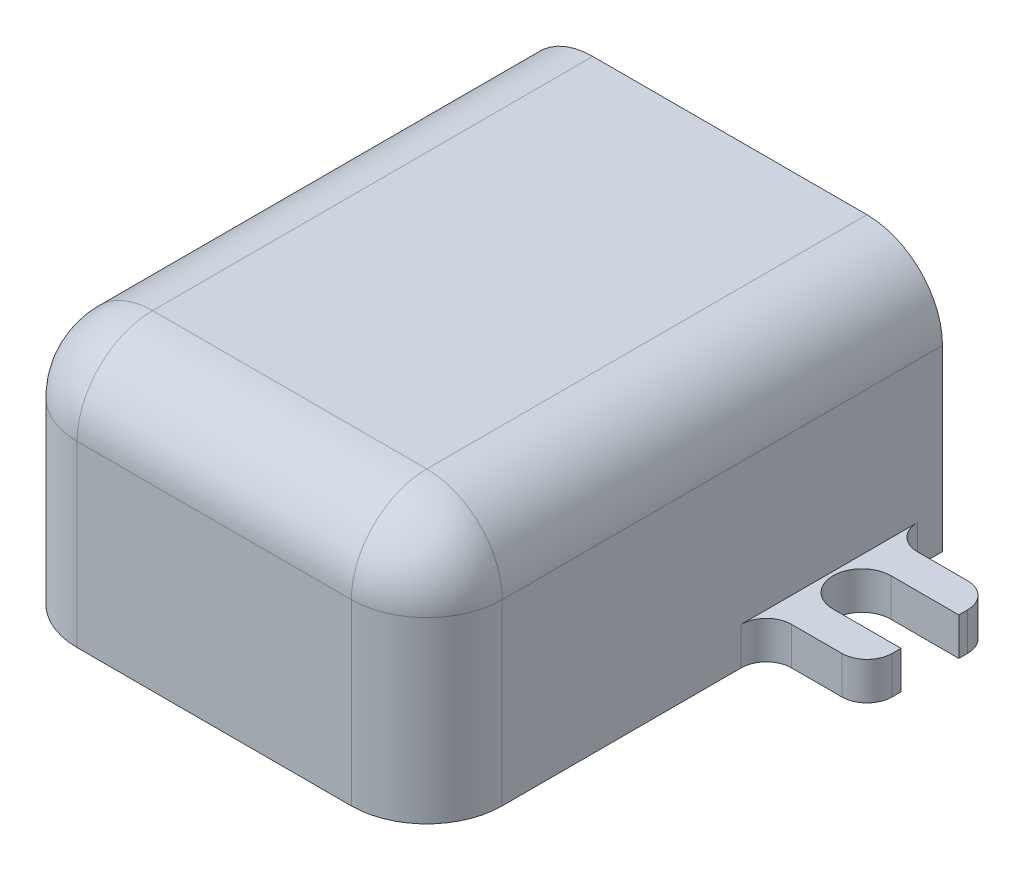
from build123d import *

# Parameters (mm, degrees)
SKETCH1_W           = 16.9
SKETCH1_H           = 20.5
BOSS_EXTRUDE1_DEPTH = 1.5
SKETCH2_W           = 16.9
SKETCH2_H           = 20.5
BOSS_EXTRUDE2_DEPTH = 8.6
FILLET1_R           = 3
FILLET2_R           = 1
SKETCH3_R           = 1.5
CUT_EXTRUDE1_DEPTH  = 10


with BuildPart() as part:
    # Sketch1 → Boss-Extrude1 (new body)
    with BuildSketch(Plane(origin=(0, 0, 0), x_dir=(1, 0, 0), z_dir=(0, 1, 0))):
        with BuildLine():
            Line((-8.45, 3.25), (-8.45, 8.25))
            Line((-8.45, 8.25), (-12.45, 8.25))
            Line((-12.45, 8.25), (-12.45, 6.9))
            Line((-12.45, 6.9), (-9.75, 6.9))
            ThreePointArc((-9.75, 6.9), (-8.936827202, 6.563172798), (-8.6, 5.75))
            ThreePointArc((-8.6, 5.75), (-8.936827202, 4.936827202), (-9.75, 4.6))
            Line((-9.75, 4.6), (-12.45, 4.6))
            Line((-12.45, 4.6), (-12.45, 3.25))
            Line((-12.45, 3.25), (-8.45, 3.25))
        make_face()
        Rectangle(SKETCH1_W, SKETCH1_H)
        with BuildLine():
            Line((12.45, 8.25), (8.45, 8.25))
            Line((8.45, 8.25), (8.45, 3.25))
            Line((8.45, 3.25), (12.45, 3.25))
            Line((12.45, 3.25), (12.45, 4.6))
            Line((12.45, 4.6), (9.75, 4.6))
            ThreePointArc((9.75, 4.6), (8.6, 5.75), (9.75, 6.9))
            Line((9.75, 6.9), (12.45, 6.9))
            Line((12.45, 6.9), (12.45, 8.25))
        make_face()
    extrude(amount=BOSS_EXTRUDE1_DEPTH)

    # Sketch2 → Boss-Extrude2 (add)
    with BuildSketch(Plane(origin=(0, 1.5, 0), x_dir=(1, 0, 0), z_dir=(0, 1, 0))):
        Rectangle(SKETCH2_W, SKETCH2_H)
    extrude(amount=BOSS_EXTRUDE2_DEPTH)

    # Fillet1
    fillet1_edges = [part.edges().sort_by_distance(p)[0] for p in [
        (8.45, 5.05, 10.25),
        (-8.45, 5.05, 10.25),
        (-8.45, 10.1, 0),
        (0, 10.1, 10.25),
        (8.45, 10.1, 0),
    ]]
    fillet(fillet1_edges, radius=FILLET1_R)

    # Fillet2
    fillet2_edges = [part.edges().sort_by_distance(p)[0] for p in [
        (-12.45, 0.75, -8.25),
        (-8.45, 0.75, -8.25),
        (8.45, 0.75, -8.25),
        (12.45, 0.75, -8.25),
        (12.45, 0.75, -3.25),
        (8.45, 0.75, -3.25),
        (-8.45, 0.75, -3.25),
        (-12.45, 0.75, -3.25),
    ]]
    fillet(fillet2_edges, radius=FILLET2_R)

    # Sketch3 → Cut-Extrude1 (cut)
    with BuildSketch(Plane(origin=(0, 0, -10.25), x_dir=(-1, 0, 0), z_dir=(0, 0, -1))):
        Polygon((7.5, 4.05), (7.5, 6.05), (6, 7.55), (-7.5, 7.55), (-7.5, 2.55), (6, 2.55), align=None)
        with Locations((-3.6, 5.05)):
            Circle(SKETCH3_R, mode=Mode.SUBTRACT)
        with Locations((3.6, 5.05)):
            Circle(SKETCH3_R, mode=Mode.SUBTRACT)
    extrude(amount=-CUT_EXTRUDE1_DEPTH, mode=Mode.SUBTRACT)


solid = part.part
